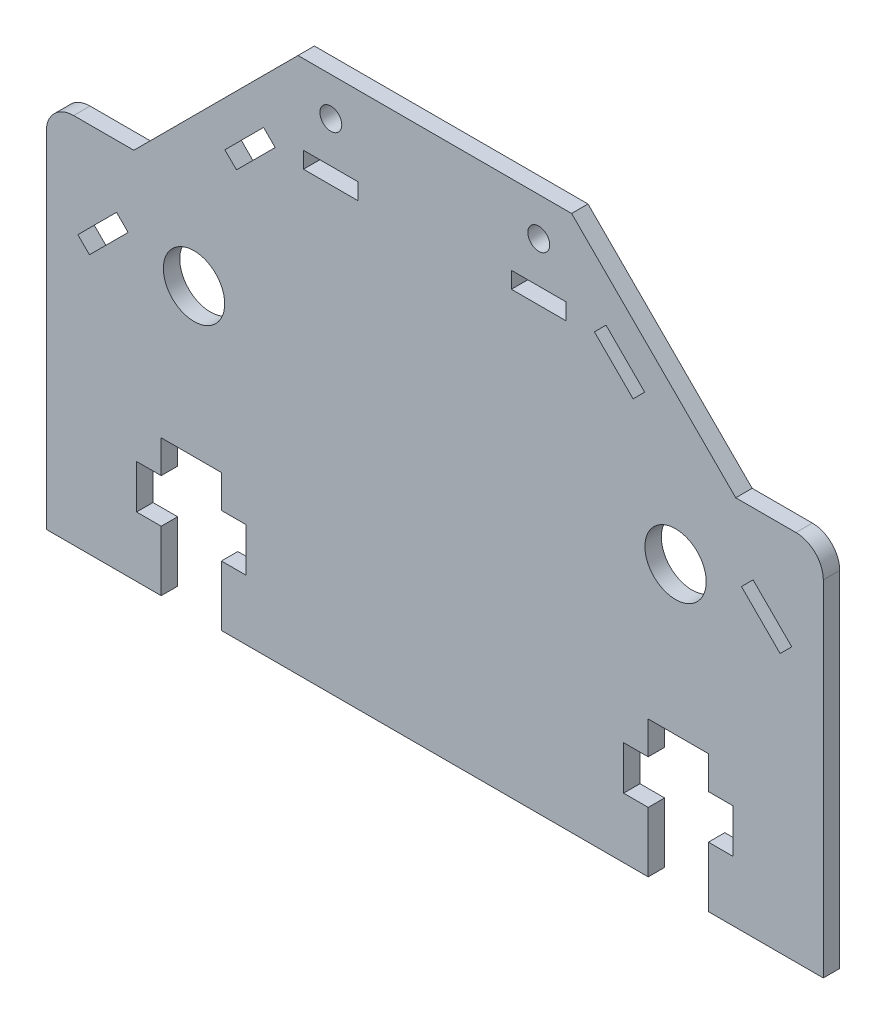
from build123d import *

# Parameters (mm, degrees)
MODEL_R                 = 5.602685567
MODEL_R_2               = 2
MODEL_W                 = 10
MODEL_H                 = 3
SALIENTE_EXTRUIR1_DEPTH = 3


with BuildPart() as part:
    # Model → Saliente-Extruir1 (new body)
    with BuildSketch(Plane.XY):
        with BuildLine():
            Line((-237.074609356, -49.671573713), (-258.074609356, -49.671573713))
            Line((-258.074609356, -49.671573713), (-258.074609356, 13.328426287))
            ThreePointArc((-258.074609356, 13.328426287), (-256.610143262, 16.863960193), (-253.074609356, 18.328426287))
            Line((-253.074609356, 18.328426287), (-242.074609356, 18.328426287))
            Line((-242.074609356, 18.328426287), (-212.074609356, 48.328426287))
            Line((-212.074609356, 48.328426287), (-162.074609356, 48.328426287))
            Line((-162.074609356, 48.328426287), (-132.074609356, 18.328426287))
            Line((-132.074609356, 18.328426287), (-121.074609356, 18.328426287))
            ThreePointArc((-121.074609356, 18.328426287), (-117.53907545, 16.863960193), (-116.074609356, 13.328426287))
            Line((-116.074609356, 13.328426287), (-116.074609356, -49.671573713))
            Line((-116.074609356, -49.671573713), (-137.074609356, -49.671573713))
            Line((-137.074609356, -49.671573713), (-137.074609356, -38.671573713))
            Line((-137.074609356, -38.671573713), (-132.574609356, -38.671573713))
            Line((-132.574609356, -38.671573713), (-132.574609356, -30.671573713))
            Line((-132.574609356, -30.671573713), (-137.074609356, -30.671573713))
            Line((-137.074609356, -30.671573713), (-137.074609356, -24.671573713))
            Line((-137.074609356, -24.671573713), (-148.074609356, -24.671573713))
            Line((-148.074609356, -24.671573713), (-148.074609356, -30.671573713))
            Line((-148.074609356, -30.671573713), (-152.574609356, -30.671573713))
            Line((-152.574609356, -30.671573713), (-152.574609356, -38.671573713))
            Line((-152.574609356, -38.671573713), (-148.074609356, -38.671573713))
            Line((-148.074609356, -38.671573713), (-148.074609356, -49.671573713))
            Line((-148.074609356, -49.671573713), (-226.074609356, -49.671573713))
            Line((-226.074609356, -49.671573713), (-226.074609356, -38.671573713))
            Line((-226.074609356, -38.671573713), (-221.574609356, -38.671573713))
            Line((-221.574609356, -38.671573713), (-221.574609356, -30.671573713))
            Line((-221.574609356, -30.671573713), (-226.074609356, -30.671573713))
            Line((-226.074609356, -30.671573713), (-226.074609356, -24.671573713))
            Line((-226.074609356, -24.671573713), (-237.074609356, -24.671573713))
            Line((-237.074609356, -24.671573713), (-237.074609356, -30.671573713))
            Line((-237.074609356, -30.671573713), (-241.574609356, -30.671573713))
            Line((-241.574609356, -30.671573713), (-241.574609356, -38.671573713))
            Line((-241.574609356, -38.671573713), (-237.074609356, -38.671573713))
            Line((-237.074609356, -38.671573713), (-237.074609356, -49.671573713))
        make_face()
        with Locations((-231.074609356, 2.328426287)):
            Circle(MODEL_R, mode=Mode.SUBTRACT)
        with Locations((-143.074609356, 2.328426287)):
            Circle(MODEL_R, mode=Mode.SUBTRACT)
        with Locations((-168.074609356, 41.328426287)):
            Circle(MODEL_R_2, mode=Mode.SUBTRACT)
        with Locations((-206.074609356, 41.328426287)):
            Circle(MODEL_R_2, mode=Mode.SUBTRACT)
        Polygon((-157.905285481, 31.673821038), (-150.834217669, 24.602753226), (-148.712897325, 26.724073569), (-155.783965137, 33.795141381), align=None, mode=Mode.SUBTRACT)
        Polygon((-250.185058728, -2.267304459), (-243.113990916, 4.803763352), (-245.23531126, 6.925083696), (-252.306379072, -0.145984116), align=None, mode=Mode.SUBTRACT)
        with Locations((-206.074609356, 32.328426287)):
            Rectangle(MODEL_W, MODEL_H, mode=Mode.SUBTRACT)
        Polygon((-123.964159984, -2.267304459), (-131.035227796, 4.803763352), (-128.913907452, 6.925083696), (-121.84283964, -0.145984116), align=None, mode=Mode.SUBTRACT)
        Polygon((-216.243933231, 31.673821038), (-223.315001043, 24.602753226), (-225.436321387, 26.724073569), (-218.365253575, 33.795141381), align=None, mode=Mode.SUBTRACT)
        with Locations((-168.074609356, 32.328426287)):
            Rectangle(MODEL_W, MODEL_H, mode=Mode.SUBTRACT)
    extrude(amount=SALIENTE_EXTRUIR1_DEPTH)


solid = part.part
